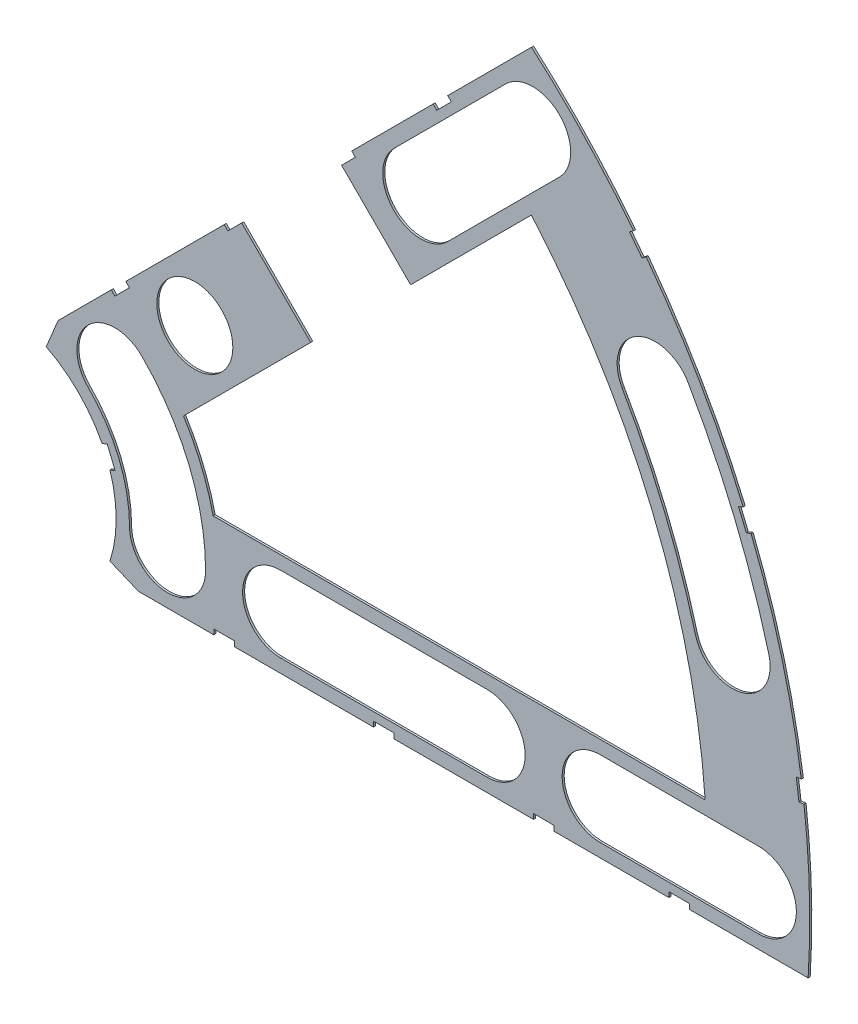
from build123d import *

# Parameters (mm, degrees)
BOSS_EXTRUDE1_DEPTH = 0.254
SKETCH2_R           = 4.699
CUT_EXTRUDE1_DEPTH  = 1.254
SKETCH3_W           = 2.54
SKETCH3_H           = 0.635
CUT_EXTRUDE2_DEPTH  = 1.254
CUT_EXTRUDE4_DEPTH  = 1.254
CUT_EXTRUDE5_DEPTH  = 1.254


with BuildPart() as part:
    # Sketch1 → Boss-Extrude1 (new body)
    with BuildSketch(Plane.XY):
        with BuildLine():
            Line((67.21146711, 76.191723231), (8.696654013, 17.676910134))
            Line((8.696654013, 17.676910134), (7.228954972, 14.133571205))
            ThreePointArc((7.228954972, 14.133571205), (14.666587579, 6.075099489), (15.105587123, -4.88230096))
            Line((15.105587123, -4.88230096), (18.648926052, -6.35))
            Line((18.648926052, -6.35), (101.401368334, -6.35))
            ThreePointArc((101.401368334, -6.35), (93.866160503, 38.880636728), (67.21146711, 76.191723231))
        make_face()
        with BuildLine():
            Line((88.672924278, 6.35), (27.86051193, 6.35))
            ThreePointArc((27.86051193, 6.35), (26.399857642, 10.93517908), (24.190484974, 15.210228852))
            Line((24.190484974, 15.210228852), (67.191354125, 58.211098004))
            ThreePointArc((67.191354125, 58.211098004), (82.13289044, 34.020557137), (88.672924278, 6.35))
        make_face(mode=Mode.SUBTRACT)
    extrude(amount=BOSS_EXTRUDE1_DEPTH)

    # Sketch2 → Cut-Extrude1 (cut, through all)
    with BuildSketch(Plane.XY.offset(0.254)):
        with Locations((22.225, 0)):
            Circle(SKETCH2_R)
        with Locations((36.195, 0)):
            Circle(SKETCH2_R)
        with Locations((61.722, 0)):
            Circle(SKETCH2_R)
        with Locations((75.692, 0)):
            Circle(SKETCH2_R)
        with Locations((95.25, 0)):
            Circle(SKETCH2_R)
        with Locations((15.715448212, 15.715448212)):
            Circle(SKETCH2_R)
        with Locations((25.593729945, 25.593729945)):
            Circle(SKETCH2_R)
        with Locations((43.644044748, 43.644044748)):
            Circle(SKETCH2_R)
        with Locations((53.522326482, 53.522326482)):
            Circle(SKETCH2_R)
        with Locations((92.004434954, 24.652514046)):
            Circle(SKETCH2_R)
        with Locations((82.48891971, 47.625)):
            Circle(SKETCH2_R)
        with Locations((67.351920908, 67.351920908)):
            Circle(SKETCH2_R)
    extrude(amount=-CUT_EXTRUDE1_DEPTH, mode=Mode.SUBTRACT)

    # Sketch3 → Cut-Extrude2 (cut, through all)
    with BuildSketch(Plane.XY.offset(0.254)):
        Polygon((15.266435406, 24.246691527), (17.06248663, 26.042742751), (17.511499436, 25.593729945), (15.715448212, 23.797678721), align=None)
        Polygon((44.991083167, 53.971339288), (43.195031942, 52.175288063), (43.644044748, 51.726275257), (45.440095973, 53.522326482), align=None)
        with Locations((29.21, -6.0325)):
            Rectangle(SKETCH3_W, SKETCH3_H)
        with Locations((68.707, -6.0325)):
            Rectangle(SKETCH3_W, SKETCH3_H)
        Polygon((29.230733674, 38.210989795), (31.026784898, 40.007041019), (31.475797704, 39.558028213), (29.67974648, 37.761976989), align=None)
        Polygon((56.845021246, 65.825277367), (55.048970022, 64.029226143), (55.497982828, 63.580213337), (57.294034052, 65.376264561), align=None)
        with Locations((48.9585, -6.0325)):
            Rectangle(SKETCH3_W, SKETCH3_H)
        with Locations((85.471, -6.0325)):
            Rectangle(SKETCH3_W, SKETCH3_H)
        Polygon((99.935462164, 14.437711971), (100.266998693, 11.919442024), (101.526133667, 12.085210288), (101.194597138, 14.603480236), align=None)
        Polygon((93.765504959, 37.464305742), (94.938831965, 37.950313702), (93.966816047, 40.296967714), (92.793489041, 39.810959755), align=None)
        Polygon((79.327792988, 62.471156422), (80.874047017, 60.456038938), (81.88160576, 61.229165953), (80.33535173, 63.244283437), align=None)
        Polygon((13.593916116, 7.005422516), (14.565932035, 4.658768503), (15.739259041, 5.144776462), (14.767243123, 7.491430475), align=None)
    extrude(amount=-CUT_EXTRUDE2_DEPTH, mode=Mode.SUBTRACT)

    # Sketch6 → Cut-Extrude4 (cut, through all)
    with BuildSketch(Plane.XY.offset(0.254)):
        with BuildLine():
            Line((50.199631717, 56.845021246), (64.029226143, 70.674615673))
            ThreePointArc((64.029226143, 70.674615673), (70.674615673, 70.674615673), (70.674615673, 64.029226143))
            Line((70.674615673, 64.029226143), (56.845021246, 50.199631717))
            ThreePointArc((56.845021246, 50.199631717), (50.199631717, 50.199631717), (50.199631717, 56.845021246))
        make_face()
        with BuildLine():
            Line((61.722, -4.699), (36.195, -4.699))
            ThreePointArc((36.195, -4.699), (31.496, 0), (36.195, 4.699))
            Line((36.195, 4.699), (61.722, 4.699))
            ThreePointArc((61.722, 4.699), (66.421, 0), (61.722, -4.699))
        make_face()
        with BuildLine():
            Line((95.25, -4.699), (75.692, -4.699))
            ThreePointArc((75.692, -4.699), (70.993, 0), (75.692, 4.699))
            Line((75.692, 4.699), (95.25, 4.699))
            ThreePointArc((95.25, 4.699), (99.949, 0), (95.25, -4.699))
        make_face()
        with BuildLine():
            ThreePointArc((26.924, 0), (24.874532533, 10.303368733), (19.038142977, 19.038142977))
            ThreePointArc((19.038142977, 19.038142977), (12.392753447, 19.038142977), (12.392753447, 12.392753447))
            ThreePointArc((12.392753447, 12.392753447), (16.191912687, 6.706909836), (17.526, 0))
            ThreePointArc((17.526, 0), (22.225, -4.699), (26.924, 0))
        make_face()
        with BuildLine():
            ThreePointArc((96.543320412, 25.868704739), (92.340835395, 38.248826381), (86.558373083, 49.9745))
            ThreePointArc((86.558373083, 49.9745), (80.13941971, 51.694453372), (78.419466338, 45.2755))
            ThreePointArc((78.419466338, 45.2755), (83.658215548, 34.652367484), (87.465549496, 23.436323353))
            ThreePointArc((87.465549496, 23.436323353), (93.220625647, 20.113628588), (96.543320412, 25.868704739))
        make_face()
    extrude(amount=-CUT_EXTRUDE4_DEPTH, mode=Mode.SUBTRACT)

    # Sketch5 → Cut-Extrude5 (cut, through all)
    with BuildSketch(Plane.XY.offset(0.254)):
        Polygon((30.038956725, 40.81526407), (42.386808891, 53.163116237), (53.163116237, 42.386808891), (40.81526407, 30.038956725), align=None)
    extrude(amount=-CUT_EXTRUDE5_DEPTH, mode=Mode.SUBTRACT)


solid = part.part
